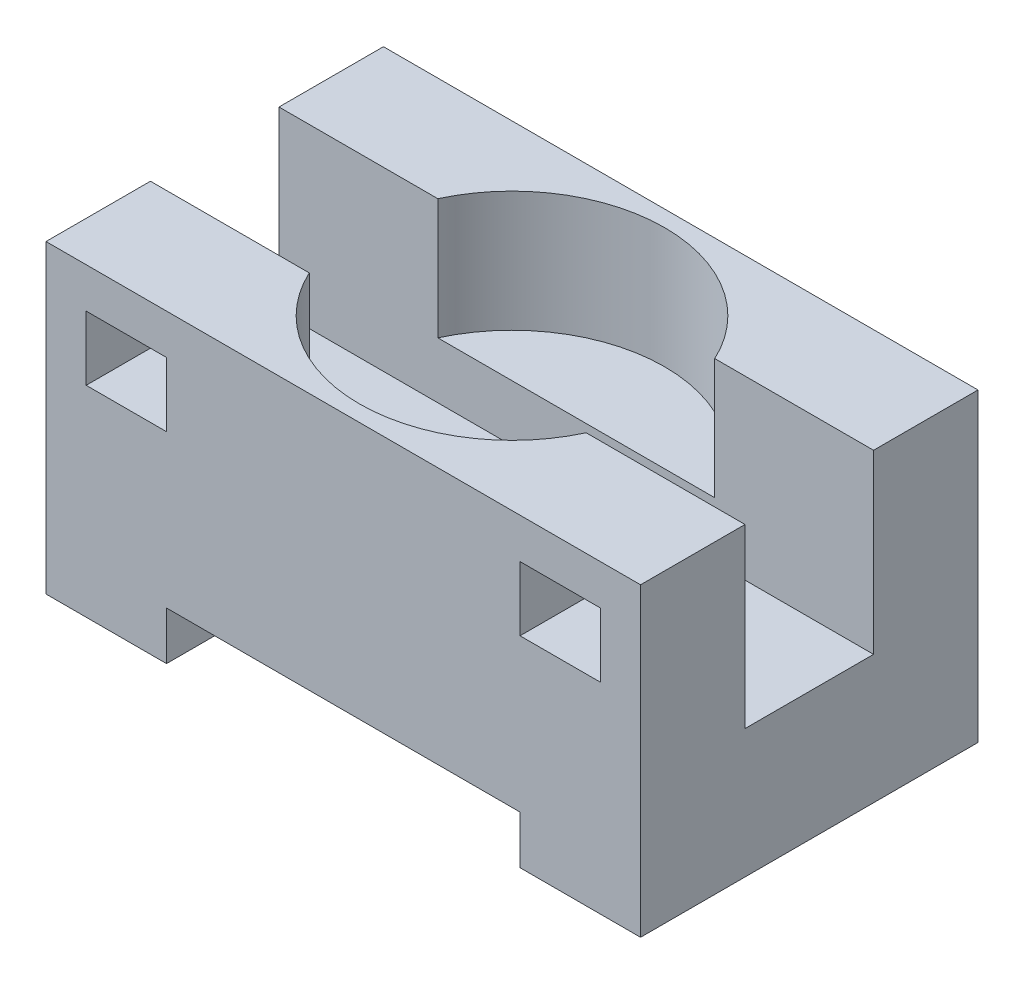
from build123d import *

# Parameters (mm, degrees)
SKETCH1_W           = 74
SKETCH1_H           = 38
BOSS_EXTRUDE1_DEPTH = 42
SKETCH2_W           = 44
SKETCH2_H           = 6
CUT_EXTRUDE1_DEPTH  = 42
SKETCH3_W           = 16
SKETCH3_H           = 22
CUT_EXTRUDE2_DEPTH  = 74
SKETCH4_R           = 19
CUT_EXTRUDE3_DEPTH  = 15
SKETCH5_W           = 10
SKETCH5_H           = 8
CUT_EXTRUDE4_DEPTH  = 15


with BuildPart() as part:
    # Sketch1 → Boss-Extrude1 (new body)
    with BuildSketch(Plane.XY):
        Rectangle(SKETCH1_W, SKETCH1_H)
    extrude(amount=BOSS_EXTRUDE1_DEPTH)

    # Sketch2 → Cut-Extrude1 (cut)
    with BuildSketch(Plane(origin=(0, 0, 0), x_dir=(-1, 0, 0), z_dir=(0, 0, -1))):
        with Locations((0, -16)):
            Rectangle(SKETCH2_W, SKETCH2_H)
    extrude(amount=-CUT_EXTRUDE1_DEPTH, mode=Mode.SUBTRACT)

    # Sketch3 → Cut-Extrude2 (cut)
    with BuildSketch(Plane(origin=(37, 0, 0), x_dir=(0, 0, -1), z_dir=(1, 0, 0))):
        with Locations((-21, 8)):
            Rectangle(SKETCH3_W, SKETCH3_H)
    extrude(amount=-CUT_EXTRUDE2_DEPTH, mode=Mode.SUBTRACT)

    # Sketch4 → Cut-Extrude3 (cut)
    with BuildSketch(Plane(origin=(0, 19, 0), x_dir=(1, 0, 0), z_dir=(0, 1, 0))):
        with Locations((0, -21)):
            Circle(SKETCH4_R)
    extrude(amount=-CUT_EXTRUDE3_DEPTH, mode=Mode.SUBTRACT)

    # Sketch5 → Cut-Extrude4 (cut)
    with BuildSketch(Plane.XY.offset(42)):
        with Locations((-27, 10)):
            Rectangle(SKETCH5_W, SKETCH5_H)
        with Locations((27, 10)):
            Rectangle(SKETCH5_W, SKETCH5_H)
    extrude(amount=-CUT_EXTRUDE4_DEPTH, mode=Mode.SUBTRACT)


solid = part.part
